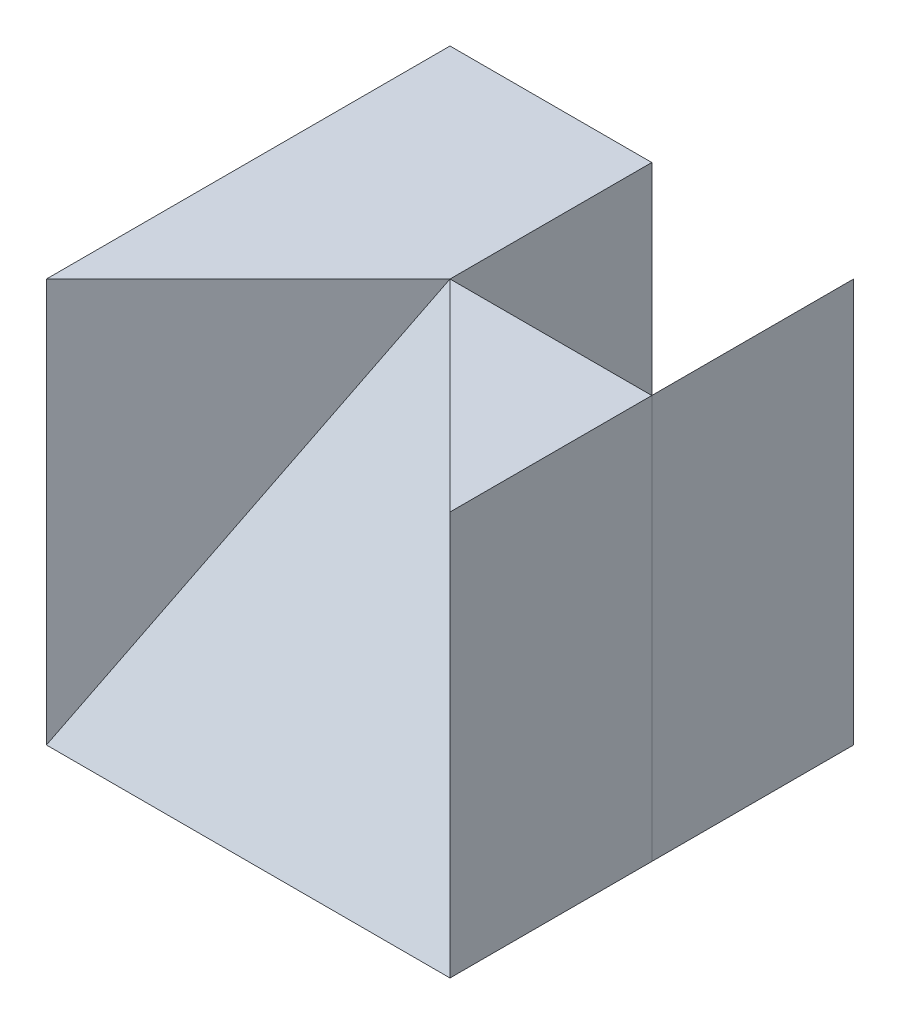
from build123d import *

# Parameters (mm, degrees)
SKETCH2_W           = 4
SKETCH2_H           = 4
BOSS_EXTRUDE1_DEPTH = 4
CUT_EXTRUDE1_DEPTH  = 10
SKETCH5_W           = 2
SKETCH5_H           = 2
CUT_EXTRUDE5_DEPTH  = 10
BOSS_EXTRUDE4_DEPTH = 2


with BuildPart() as part:
    # Sketch2 → Boss-Extrude1 (new body)
    with BuildSketch(Plane(origin=(0, 0, 0), x_dir=(1, 0, 0), z_dir=(0, 1, 0))):
        Rectangle(SKETCH2_W, SKETCH2_H)
    extrude(amount=BOSS_EXTRUDE1_DEPTH)

    # 3DSketch1 → Cut-Extrude1 (cut, along a direction that is not the sketch's normal)
    with BuildSketch(Plane(origin=(-2, 0, 2), x_dir=(0.4082482904638631, 0.8164965809277261, -0.4082482904638631), z_dir=(0, -0.447213595499958, -0.894427190999916))):
        Polygon((0, 0), (4.898979486, 0), (1.632993162, 3.651483717), align=None)
    extrude(amount=-CUT_EXTRUDE1_DEPTH, dir=(0, -1, 0), mode=Mode.SUBTRACT)

    # Sketch5 → Cut-Extrude5 (cut)
    with BuildSketch(Plane(origin=(0, 4, 0), x_dir=(1, 0, 0), z_dir=(0, 1, 0))):
        with Locations((1, 1)):
            Rectangle(SKETCH5_W, SKETCH5_H)
    extrude(amount=-CUT_EXTRUDE5_DEPTH, mode=Mode.SUBTRACT)


with BuildPart() as body_2:
    # Sketch6 → Boss-Extrude4 (new body)
    with BuildSketch(Plane(origin=(0, 0, 0), x_dir=(-1, 0, 0), z_dir=(0, 0, -1))):
        Polygon((-2, 4), (0, 0), (-2, 0), align=None)
    extrude(amount=BOSS_EXTRUDE4_DEPTH)


solid = Compound([part.part, body_2.part])
